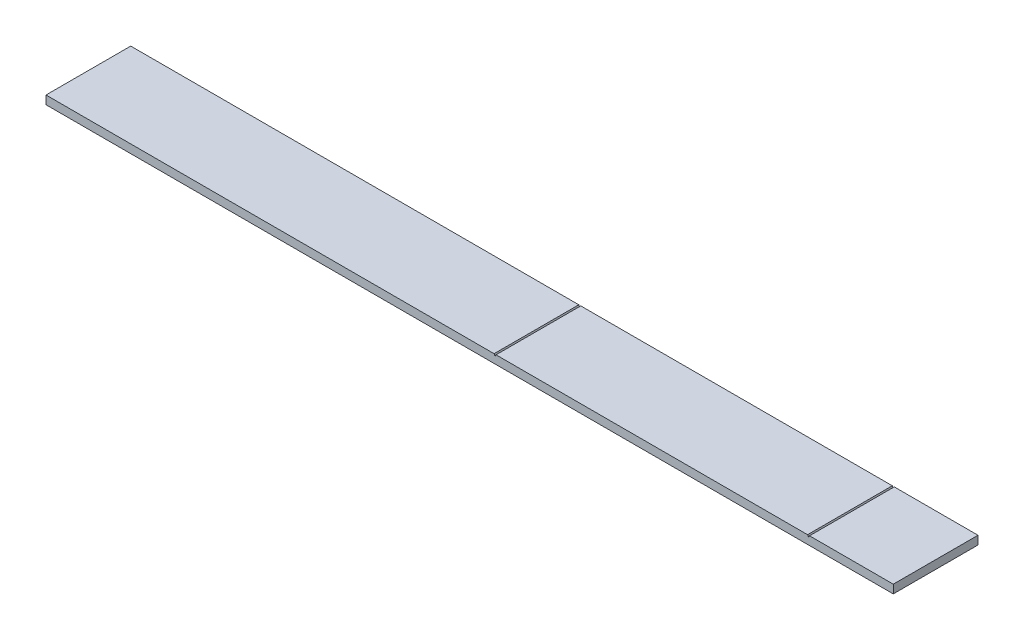
from build123d import *

# Parameters (mm, degrees)
BOSS_EXTRUDE1_DEPTH = 100


with BuildPart() as part:
    # Sketch1 → Boss-Extrude1 (new body)
    with BuildSketch(Plane.XY):
        Polygon((0, 0), (528.845299462, 0), (530, -2), (531.154700538, 0), (898.845299462, 0), (900, -2), (901.154700538, 0), (1000, 0), (1000, -10), (0, -10), align=None)
    extrude(amount=BOSS_EXTRUDE1_DEPTH)


solid = part.part
